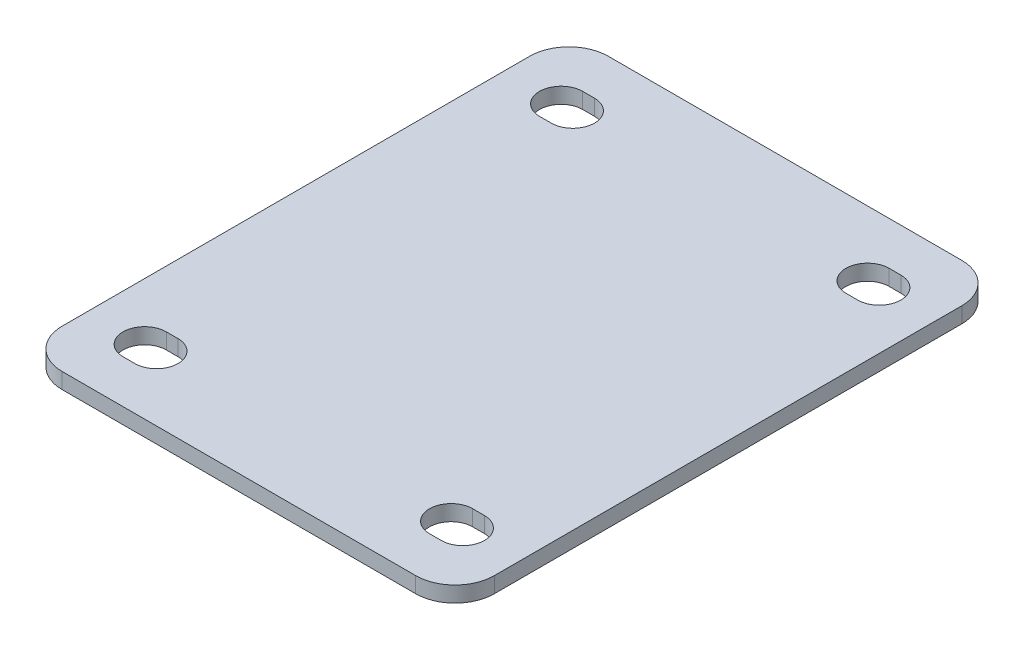
from build123d import *

# Parameters (mm, degrees)
SKETCH1_W           = 110
SKETCH1_H           = 139
BOSS_EXTRUDE1_DEPTH = 4
FILLET1_R           = 10


with BuildPart() as part:
    # Sketch1 → Boss-Extrude1 (new body)
    with BuildSketch(Plane(origin=(0, 0, 0), x_dir=(1, 0, 0), z_dir=(0, 1, 0))):
        Rectangle(SKETCH1_W, SKETCH1_H)
        with BuildLine():
            Line((-40.5, 58.5), (-37.5, 58.5))
            ThreePointArc((-37.5, 58.5), (-32, 53), (-37.5, 47.5))
            Line((-37.5, 47.5), (-40.5, 47.5))
            ThreePointArc((-40.5, 47.5), (-46, 53), (-40.5, 58.5))
        make_face(mode=Mode.SUBTRACT)
        with BuildLine():
            Line((37.5, 58.5), (40.5, 58.5))
            ThreePointArc((40.5, 58.5), (46, 53), (40.5, 47.5))
            Line((40.5, 47.5), (37.5, 47.5))
            ThreePointArc((37.5, 47.5), (32, 53), (37.5, 58.5))
        make_face(mode=Mode.SUBTRACT)
        with BuildLine():
            Line((-40.5, -47.5), (-37.5, -47.5))
            ThreePointArc((-37.5, -47.5), (-32, -53), (-37.5, -58.5))
            Line((-37.5, -58.5), (-40.5, -58.5))
            ThreePointArc((-40.5, -58.5), (-46, -53), (-40.5, -47.5))
        make_face(mode=Mode.SUBTRACT)
        with BuildLine():
            Line((37.5, -47.5), (40.5, -47.5))
            ThreePointArc((40.5, -47.5), (46, -53), (40.5, -58.5))
            Line((40.5, -58.5), (37.5, -58.5))
            ThreePointArc((37.5, -58.5), (32, -53), (37.5, -47.5))
        make_face(mode=Mode.SUBTRACT)
    extrude(amount=BOSS_EXTRUDE1_DEPTH)

    # Fillet1
    fillet1_edges = [part.edges().sort_by_distance(p)[0] for p in [
        (55, 2, 69.5),
        (-55, 2, 69.5),
        (-55, 2, -69.5),
        (55, 2, -69.5),
    ]]
    fillet(fillet1_edges, radius=FILLET1_R)


solid = part.part
